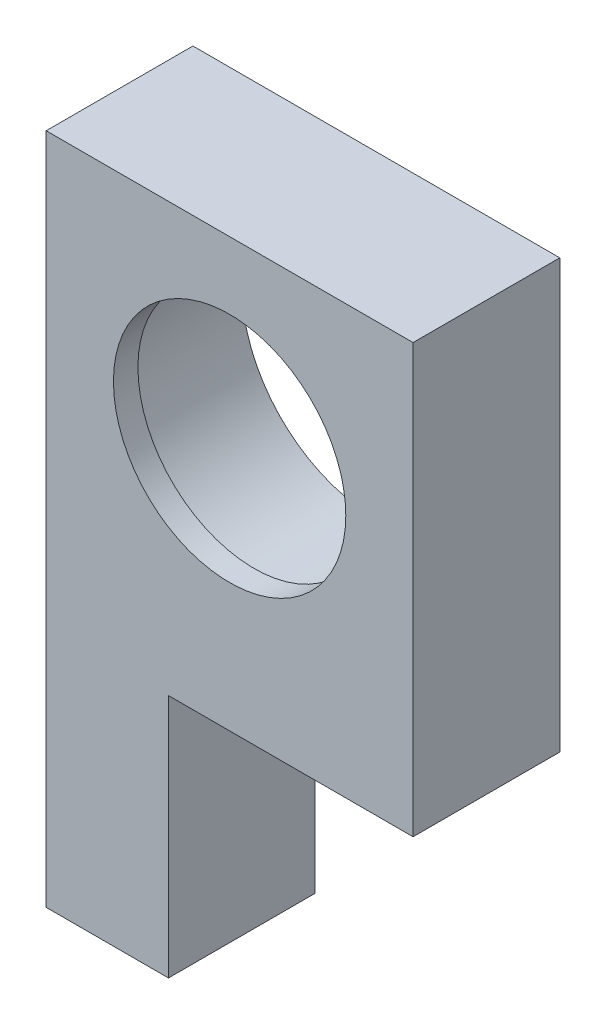
from build123d import *

# Parameters (mm, degrees)
SKIZZE1_R                       = 9.5
AUFSATZ_LINEAR_AUSTRAGEN2_DEPTH = 12
SKIZZE9_R                       = 11
SCHNITT_LINEAR_AUSTRAGEN2_DEPTH = 10


with BuildPart() as part:
    # Skizze1 → Aufsatz-Linear austragen2 (new body)
    with BuildSketch(Plane.XY):
        Polygon((15, 15), (-15, 15), (-15, -40), (-5, -40), (-5, -20), (15, -20), align=None)
        Circle(SKIZZE1_R, mode=Mode.SUBTRACT)
    extrude(amount=AUFSATZ_LINEAR_AUSTRAGEN2_DEPTH)

    # Skizze9 → Schnitt-Linear austragen2 (cut)
    with BuildSketch(Plane(origin=(0, 0, 0), x_dir=(-1, 0, 0), z_dir=(0, 0, -1))):
        Circle(SKIZZE9_R)
    extrude(amount=-SCHNITT_LINEAR_AUSTRAGEN2_DEPTH, mode=Mode.SUBTRACT)


solid = part.part
